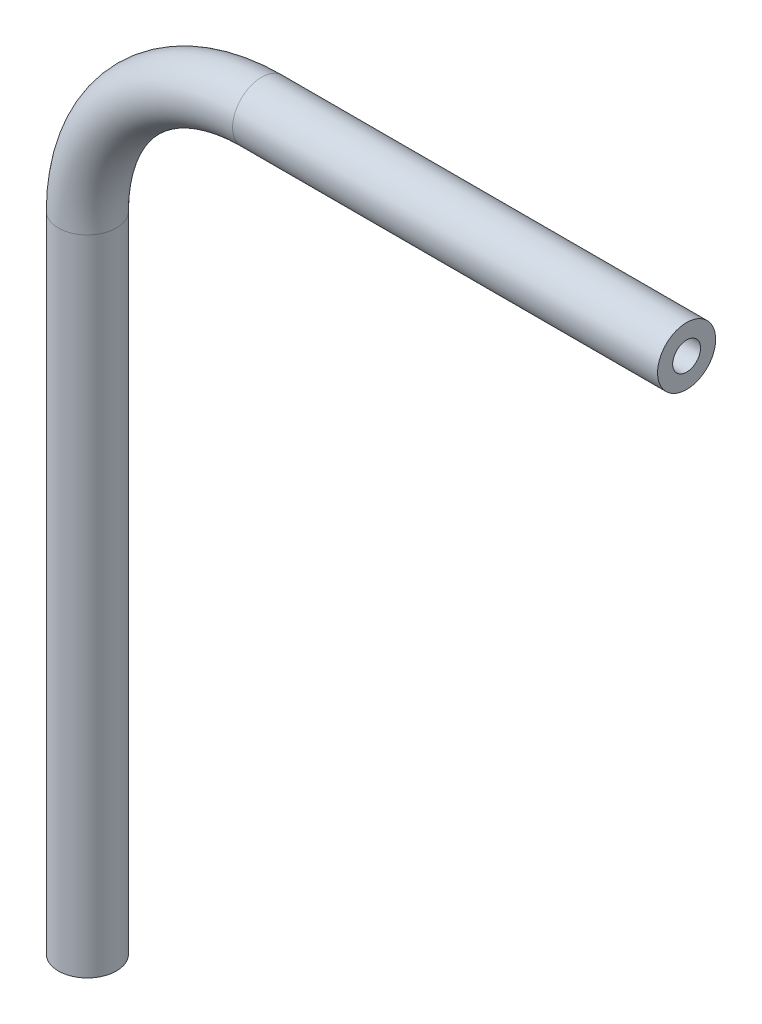
from build123d import *

# Parameters (mm, degrees)
SKETCH2_R   = 3.175
SKETCH2_R_2 = 1.524


with BuildPart() as part:
    # Sweep1: sweep along a path in Sketch1
    with BuildLine(Plane.XY) as sweep1_path:
        Line((0, -71.880317881), (0, -1.522317881))
        ThreePointArc((0, -1.522317881), (5.579615818, 11.948066301), (19.05, 17.527682119))
        Line((19.05, 17.527682119), (65.517903, 17.527682119))
    # Sketch2 → Sweep1 (sweep)
    with BuildSketch(Plane(origin=(65.517903, 17.527682119, 0), x_dir=(0, 0, -1), z_dir=(1, 0, 0))):
        Circle(SKETCH2_R)
        Circle(SKETCH2_R_2, mode=Mode.SUBTRACT)
    sweep(path=sweep1_path.line)


solid = part.part
